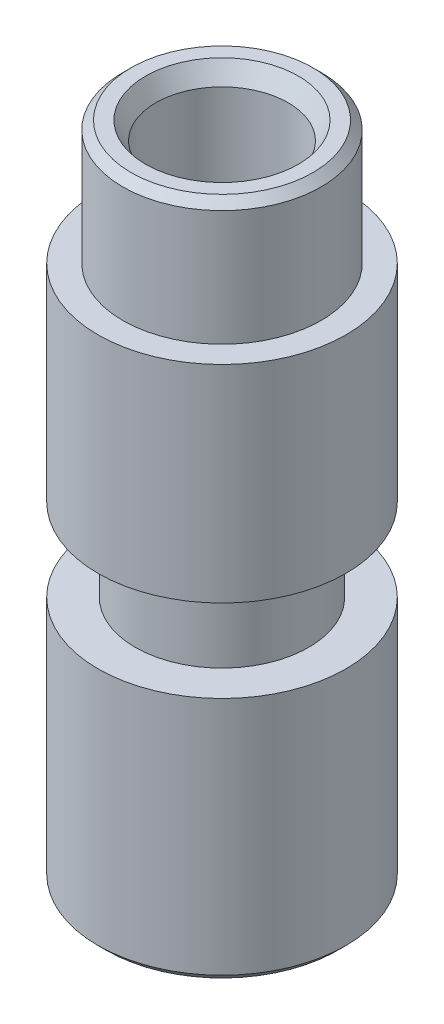
from build123d import *

# Parameters (mm, degrees)
SKETCH1_R               = 3
BOSS_EXTRUDE1_DEPTH     = 6
SKETCH2_R               = 2.1
BOSS_EXTRUDE2_DEPTH     = 2
SKETCH3_R               = 3
BOSS_EXTRUDE3_DEPTH     = 5
SKETCH4_R               = 1.6
CUT_EXTRUDE1_DEPTH      = 14
CROQUIS1_R              = 2.4
CROQUIS1_R_2            = 1.6
SALIENTE_EXTRUIR1_DEPTH = 3
CHAFL_N1_SIZE           = 0.2
CHAFL_N2_SIZE           = 0.2
CHAFL_N3_SIZE           = 0.25
CHAFL_N3_SIZE2          = 0.433012702


with BuildPart() as part:
    # Sketch1 → Boss-Extrude1 (new body)
    with BuildSketch(Plane(origin=(0, 0, 0), x_dir=(1, 0, 0), z_dir=(0, 1, 0))):
        Circle(SKETCH1_R)
    extrude(amount=BOSS_EXTRUDE1_DEPTH)

    # Sketch2 → Boss-Extrude2 (add)
    with BuildSketch(Plane(origin=(0, 6, 0), x_dir=(1, 0, 0), z_dir=(0, 1, 0))):
        Circle(SKETCH2_R)
    extrude(amount=BOSS_EXTRUDE2_DEPTH)

    # Sketch3 → Boss-Extrude3 (add)
    with BuildSketch(Plane(origin=(0, 8, 0), x_dir=(1, 0, 0), z_dir=(0, 1, 0))):
        Circle(SKETCH3_R)
    extrude(amount=BOSS_EXTRUDE3_DEPTH)

    # Sketch4 → Cut-Extrude1 (cut, through all)
    with BuildSketch(Plane(origin=(0, 13, 0), x_dir=(1, 0, 0), z_dir=(0, 1, 0))):
        Circle(SKETCH4_R)
    extrude(amount=-CUT_EXTRUDE1_DEPTH, mode=Mode.SUBTRACT)

    # Croquis1 → Saliente-Extruir1 (add)
    with BuildSketch(Plane(origin=(0, 13, 0), x_dir=(1, 0, 0), z_dir=(0, 1, 0))):
        Circle(CROQUIS1_R)
        Circle(CROQUIS1_R_2, mode=Mode.SUBTRACT)
    extrude(amount=SALIENTE_EXTRUIR1_DEPTH)

    # Chaflán1
    chafl_n1_edges = [part.edges().sort_by_distance(p)[0] for p in [
        (-2.4, 16, 0),
    ]]
    chamfer(chafl_n1_edges, length=CHAFL_N1_SIZE)

    # Chaflán2
    chafl_n2_edges = [part.edges().sort_by_distance(p)[0] for p in [
        (-3, 0, 0),
    ]]
    chamfer(chafl_n2_edges, length=CHAFL_N2_SIZE)

    # Chaflán3
    chafl_n3_edges = [part.edges().sort_by_distance(p)[0] for p in [
        (-1.6, 16, 0),
    ]]
    chafl_n3_side = [part.faces().sort_by_distance(p)[0] for p in [
        (-2.137774603, 16, 0),
    ]]
    chamfer(chafl_n3_edges, length=CHAFL_N3_SIZE, length2=CHAFL_N3_SIZE2, reference=chafl_n3_side[0])


solid = part.part
